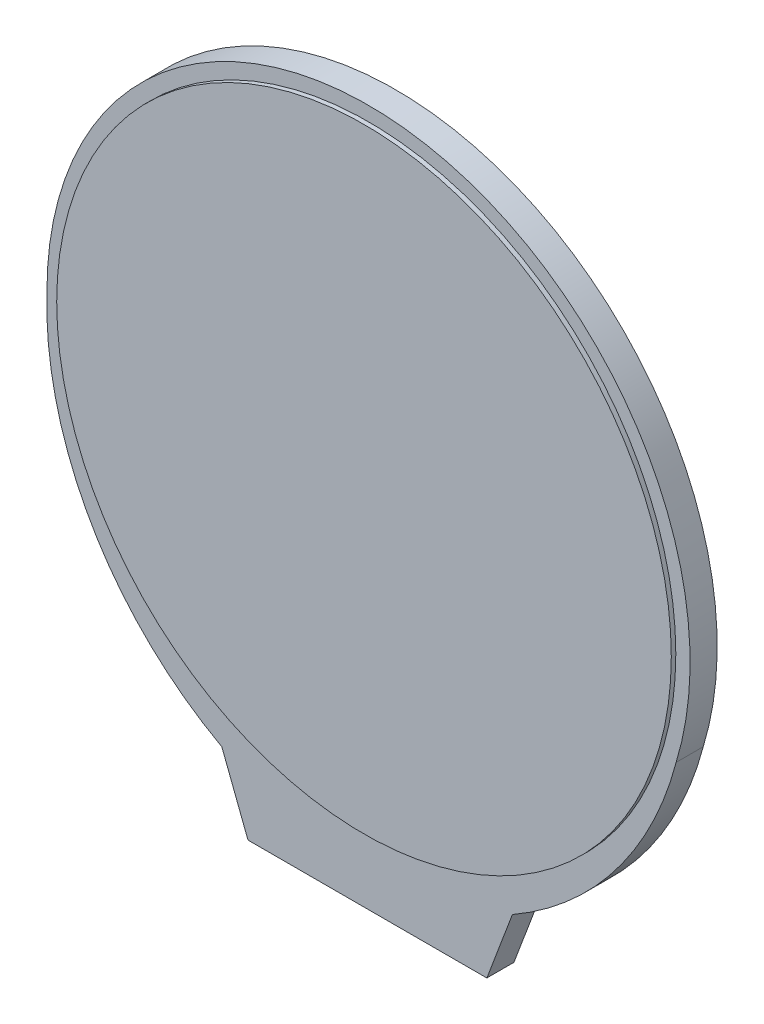
from build123d import *

# Parameters (mm, degrees)
LANGUETTE_R        = 0.598025677
LANGUETTE_R_2      = 0.602747005
BOSS_EXTRU_1_DEPTH = 0.25
CONTACTS_W         = 8.310994675
CONTACTS_H         = 2.119060631
BOSS_EXTRU_2_DEPTH = 0.26
BOSS_EXTRU_3_DEPTH = 1.5
ESQUISSE7_R        = 17.010621832
BOSS_EXTRU_4_DEPTH = 0.25


with BuildPart() as part:
    # languette → Boss.-Extru.1 (new body)
    with BuildSketch(Plane.XY):
        with BuildLine():
            Line((-6.595613447, -8.888713039), (-5.615374712, -7.488966567))
            Line((-5.615374712, -7.488966567), (-5.615374712, -5.383882856))
            ThreePointArc((-5.615374712, -5.383882856), (-5.468928102, -5.030329465), (-5.115374712, -4.883882856))
            Line((-5.115374712, -4.883882856), (5.403372294, -4.883882856))
            ThreePointArc((5.403372294, -4.883882856), (5.756925685, -5.030329465), (5.903372294, -5.383882856))
            Line((5.903372294, -5.383882856), (5.903372294, -15.510913379))
            Line((5.903372294, -15.510913379), (-6.595613447, -15.510913379))
            Line((-6.595613447, -15.510913379), (-6.595613447, -8.888713039))
        make_face()
        with Locations((-5.236276709, -9.190047348)):
            Circle(LANGUETTE_R, mode=Mode.SUBTRACT)
        with Locations((4.736916901, -9.190047348)):
            Circle(LANGUETTE_R_2, mode=Mode.SUBTRACT)
    extrude(amount=-BOSS_EXTRU_1_DEPTH)

    # contacts → Boss.-Extru.2 (add)
    with BuildSketch(Plane.XY):
        with Locations((0.143998792, -5.943413172)):
            Rectangle(CONTACTS_W, CONTACTS_H)
    extrude(amount=-BOSS_EXTRU_2_DEPTH)

    # Esquisse6 → Boss.-Extru.3 (add)
    with BuildSketch(Plane.XY):
        with BuildLine():
            Line((-6.595613447, -15.510913379), (-8.043725423, -11.761859924))
            ThreePointArc((-8.043725423, -11.761859924), (-15.286364086, -4.654195518), (-17.723977577, 5.196324701))
            ThreePointArc((-17.723977577, 5.196324701), (2.671119001, 22.861069139), (17.103268201, 0.063783556))
            ThreePointArc((17.103268201, 0.063783556), (13.761328931, -6.761125674), (8.03938861, -11.761859924))
            Line((8.03938861, -11.761859924), (6.626148003, -15.510913379))
            Line((6.626148003, -15.510913379), (-6.595613447, -15.510913379))
        make_face()
    extrude(amount=BOSS_EXTRU_3_DEPTH)

    # Esquisse7 → Boss.-Extru.4 (add)
    with BuildSketch(Plane.XY.offset(1.5)):
        with Locations((0.07593762, 5.251269776)):
            Circle(ESQUISSE7_R)
    extrude(amount=BOSS_EXTRU_4_DEPTH)


solid = part.part
